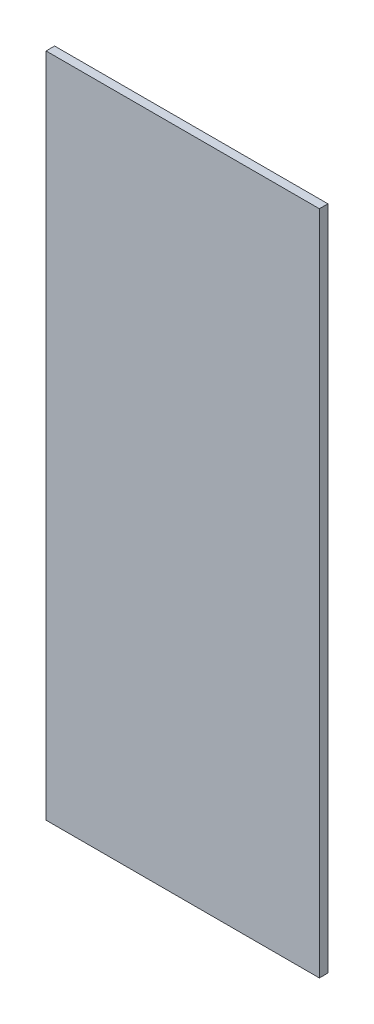
from build123d import *

# Parameters (mm, degrees)
CROQUIS2_W              = 203.2
CROQUIS2_H              = 6.35
SALIENTE_EXTRUIR1_DEPTH = 495.3


with BuildPart() as part:
    # Croquis2 → Saliente-Extruir1 (new body)
    with BuildSketch(Plane(origin=(0, 0, 0), x_dir=(1, 0, 0), z_dir=(0, 1, 0))):
        Rectangle(CROQUIS2_W, CROQUIS2_H)
    extrude(amount=SALIENTE_EXTRUIR1_DEPTH)


solid = part.part
